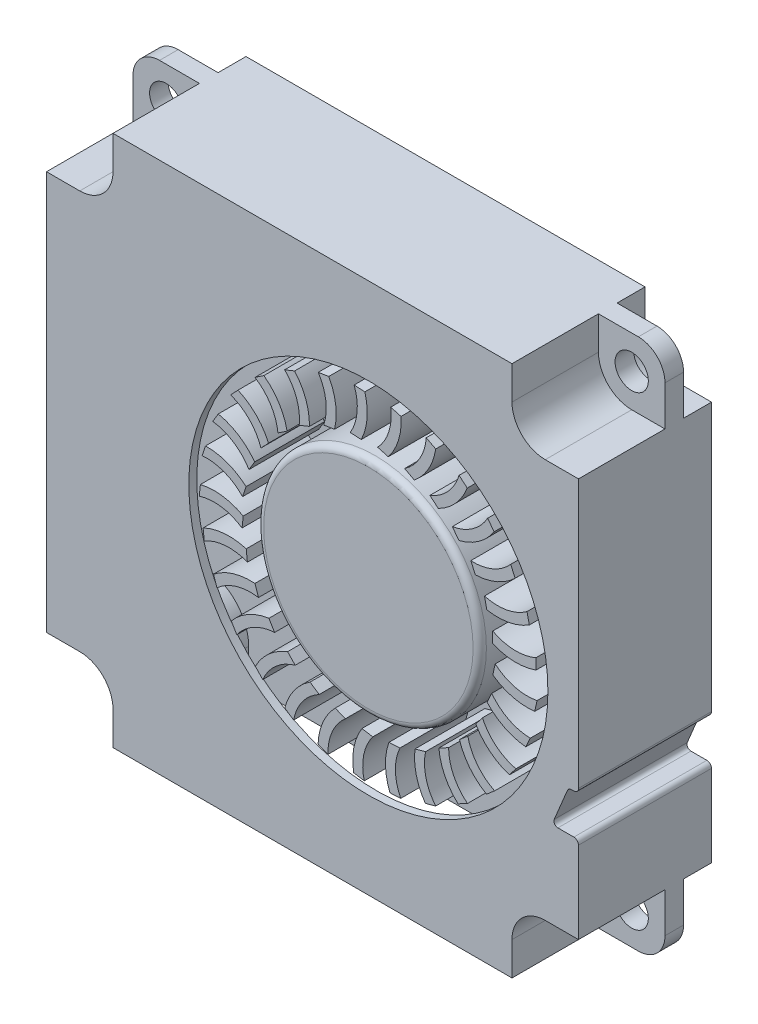
from build123d import *

# Parameters (mm, degrees)
SKETCH35_W                     = 40
SKETCH35_H                     = 40
BOSS_EXTRUDE31_DEPTH           = 10
SKETCH36_W                     = 28
SKETCH36_H                     = 8.6
CUT_EXTRUDE1_DEPTH             = 39
SKETCH41_W                     = 8.6
SKETCH41_H                     = 33
CUT_EXTRUDE2_DEPTH             = 5
SKETCH42_W                     = 8.6
SKETCH42_H                     = 33
CUT_EXTRUDE3_DEPTH             = 5
BOSS_EXTRUDE32_DEPTH           = 8.6
CUT_EXTRUDE4_DEPTH             = 11
SKETCH50_W                     = 5
SKETCH50_H                     = 5
BOSS_EXTRUDE33_DEPTH           = 8.6
SKETCH51_W                     = 5
SKETCH51_H                     = 5
BOSS_EXTRUDE34_DEPTH           = 8.6
SKETCH52_W                     = 5
SKETCH52_H                     = 5
CUT_EXTRUDE5_DEPTH             = 6.5
SKETCH53_W                     = 5
SKETCH53_H                     = 5
CUT_EXTRUDE6_DEPTH             = 6.5
SKETCH54_W                     = 5
SKETCH54_H                     = 5
CUT_EXTRUDE7_DEPTH             = 6.5
SKETCH55_W                     = 5
SKETCH55_H                     = 5
CUT_EXTRUDE8_DEPTH             = 6.5
SKETCH56_W                     = 5
SKETCH56_H                     = 5
CUT_EXTRUDE9_DEPTH             = 2.1
SKETCH57_W                     = 5
SKETCH57_H                     = 5
CUT_EXTRUDE10_DEPTH            = 2.1
SKETCH58_W                     = 5
SKETCH58_H                     = 5
CUT_EXTRUDE11_DEPTH            = 2.1
SKETCH59_W                     = 5
SKETCH59_H                     = 5
CUT_EXTRUDE12_DEPTH            = 2.1
F_2_5_2_5_DIAMETER_HOLE1_D     = 2.5
F_2_5_2_5_DIAMETER_HOLE1_DEPTH = 3.5
M24_CLEARANCE_HOLE1_D          = 27
M24_CLEARANCE_HOLE1_DEPTH      = 0.6
F_2_5_2_5_DIAMETER_HOLE2_D     = 2.5
F_2_5_2_5_DIAMETER_HOLE2_DEPTH = 7.9
FILLET2_R                      = 0.35
FILLET3_R                      = 2
FILLET4_R                      = 2.5
FILLET5_R                      = 3.5
BOSS_EXTRUDE35_DEPTH           = 2
BOSS_EXTRUDE36_DEPTH           = 5.25
BOSS_EXTRUDE37_DEPTH           = 5.25
BOSS_EXTRUDE38_DEPTH           = 5.25
BOSS_EXTRUDE39_DEPTH           = 5.25
BOSS_EXTRUDE40_DEPTH           = 5.25
BOSS_EXTRUDE41_DEPTH           = 5.25
BOSS_EXTRUDE42_DEPTH           = 5.25
BOSS_EXTRUDE43_DEPTH           = 5.25
BOSS_EXTRUDE44_DEPTH           = 5.25
BOSS_EXTRUDE45_DEPTH           = 5.25
BOSS_EXTRUDE46_DEPTH           = 5.25
BOSS_EXTRUDE47_DEPTH           = 5.25
BOSS_EXTRUDE48_DEPTH           = 5.25
BOSS_EXTRUDE49_DEPTH           = 5.25
BOSS_EXTRUDE50_DEPTH           = 5.25
BOSS_EXTRUDE51_DEPTH           = 5.25
BOSS_EXTRUDE52_DEPTH           = 5.25
BOSS_EXTRUDE53_DEPTH           = 5.25
BOSS_EXTRUDE54_DEPTH           = 5.25
BOSS_EXTRUDE55_DEPTH           = 5.25
BOSS_EXTRUDE56_DEPTH           = 5.25
BOSS_EXTRUDE57_DEPTH           = 5.25
BOSS_EXTRUDE58_DEPTH           = 5.25
BOSS_EXTRUDE59_DEPTH           = 5.25
BOSS_EXTRUDE60_DEPTH           = 5.25
BOSS_EXTRUDE61_DEPTH           = 5.25
BOSS_EXTRUDE62_DEPTH           = 5.25
BOSS_EXTRUDE63_DEPTH           = 5.25
BOSS_EXTRUDE64_DEPTH           = 5.25
SKETCH109_W                    = 8.375
SKETCH109_H                    = 5.25
FILLET6_R                      = 0.5


with BuildPart() as part:
    # Sketch35 → Boss-Extrude31 (new body)
    with BuildSketch(Plane.XY.offset(25.289004385)):
        with Locations((21.588376798, 27.405351981)):
            Rectangle(SKETCH35_W, SKETCH35_H)
    extrude(amount=-BOSS_EXTRUDE31_DEPTH)

    # Sketch36 → Cut-Extrude1 (cut)
    with BuildSketch(Plane.XZ.offset(-7.405351981)):
        with Locations((21.588376798, 20.389004385)):
            Rectangle(SKETCH36_W, SKETCH36_H)
    extrude(amount=-CUT_EXTRUDE1_DEPTH, mode=Mode.SUBTRACT)

    # Sketch41 → Cut-Extrude2 (cut)
    with BuildSketch(Plane(origin=(7.588376798, 0, 0), x_dir=(0, 0, -1), z_dir=(1, 0, 0))):
        with Locations((-20.389004385, 29.905351981)):
            Rectangle(SKETCH41_W, SKETCH41_H)
    extrude(amount=-CUT_EXTRUDE2_DEPTH, mode=Mode.SUBTRACT)

    # Sketch42 → Cut-Extrude3 (cut)
    with BuildSketch(Plane.ZY.offset(-35.588376798)):
        with Locations((20.389004385, 29.905351981)):
            Rectangle(SKETCH42_W, SKETCH42_H)
    extrude(amount=-CUT_EXTRUDE3_DEPTH, mode=Mode.SUBTRACT)

    # Sketch48 → Boss-Extrude32 (add)
    with BuildSketch(Plane(origin=(0, 0, 24.689004385), x_dir=(-1, 0, 0), z_dir=(0, 0, -1))):
        with BuildLine():
            Line((-40.588376798, 17.905351981), (-40.588376798, 22.824983073))
            ThreePointArc((-40.588376798, 22.824983073), (-40.138325562, 22.543385975), (-39.838376798, 22.105351981))
            Line((-39.838376798, 22.105351981), (-38.838376798, 19.705351981))
            ThreePointArc((-38.838376798, 19.705351981), (-38.956711416, 18.484241726), (-40.038376798, 17.905351981))
            Line((-40.038376798, 17.905351981), (-40.588376798, 17.905351981))
        make_face()
    extrude(amount=BOSS_EXTRUDE32_DEPTH)

    # Sketch49 → Cut-Extrude4 (cut, through all)
    with BuildSketch(Plane(origin=(0, 0, 15.289004385), x_dir=(-1, 0, 0), z_dir=(0, 0, -1))):
        with BuildLine():
            Line((-41.588376798, 18.905351981), (-40.038376798, 18.905351981))
            ThreePointArc((-40.038376798, 18.905351981), (-39.78876171, 19.038941923), (-39.761453721, 19.320736597))
            Line((-39.761453721, 19.320736597), (-40.838376798, 21.905351981))
            Line((-40.838376798, 21.905351981), (-41.588376798, 21.905351981))
            Line((-41.588376798, 21.905351981), (-41.588376798, 18.905351981))
        make_face()
    extrude(amount=-CUT_EXTRUDE4_DEPTH, mode=Mode.SUBTRACT)

    # Sketch50 → Boss-Extrude33 (add)
    with BuildSketch(Plane(origin=(0, 0, 24.689004385), x_dir=(-1, 0, 0), z_dir=(0, 0, -1))):
        with Locations((-38.088376798, 43.905351981)):
            Rectangle(SKETCH50_W, SKETCH50_H)
    extrude(amount=BOSS_EXTRUDE33_DEPTH)

    # Sketch51 → Boss-Extrude34 (add)
    with BuildSketch(Plane(origin=(0, 0, 24.689004385), x_dir=(-1, 0, 0), z_dir=(0, 0, -1))):
        with Locations((-5.088376798, 43.905351981)):
            Rectangle(SKETCH51_W, SKETCH51_H)
    extrude(amount=BOSS_EXTRUDE34_DEPTH)

    # Sketch52 → Cut-Extrude5 (cut)
    with BuildSketch(Plane.XY.offset(25.289004385)):
        with Locations((4.088376798, 9.905351981)):
            Rectangle(SKETCH52_W, SKETCH52_H)
    extrude(amount=-CUT_EXTRUDE5_DEPTH, mode=Mode.SUBTRACT)

    # Sketch53 → Cut-Extrude6 (cut)
    with BuildSketch(Plane.XY.offset(25.289004385)):
        with Locations((4.088376798, 44.905351981)):
            Rectangle(SKETCH53_W, SKETCH53_H)
    extrude(amount=-CUT_EXTRUDE6_DEPTH, mode=Mode.SUBTRACT)

    # Sketch54 → Cut-Extrude7 (cut)
    with BuildSketch(Plane.XY.offset(25.289004385)):
        with Locations((39.088376798, 9.905351981)):
            Rectangle(SKETCH54_W, SKETCH54_H)
    extrude(amount=-CUT_EXTRUDE7_DEPTH, mode=Mode.SUBTRACT)

    # Sketch55 → Cut-Extrude8 (cut)
    with BuildSketch(Plane.XY.offset(25.289004385)):
        with Locations((39.088376798, 44.905351981)):
            Rectangle(SKETCH55_W, SKETCH55_H)
    extrude(amount=-CUT_EXTRUDE8_DEPTH, mode=Mode.SUBTRACT)

    # Sketch56 → Cut-Extrude9 (cut)
    with BuildSketch(Plane(origin=(0, 0, 15.289004385), x_dir=(-1, 0, 0), z_dir=(0, 0, -1))):
        with Locations((-39.088376798, 44.905351981)):
            Rectangle(SKETCH56_W, SKETCH56_H)
    extrude(amount=-CUT_EXTRUDE9_DEPTH, mode=Mode.SUBTRACT)

    # Sketch57 → Cut-Extrude10 (cut)
    with BuildSketch(Plane(origin=(0, 0, 15.289004385), x_dir=(-1, 0, 0), z_dir=(0, 0, -1))):
        with Locations((-39.088376798, 9.905351981)):
            Rectangle(SKETCH57_W, SKETCH57_H)
    extrude(amount=-CUT_EXTRUDE10_DEPTH, mode=Mode.SUBTRACT)

    # Sketch58 → Cut-Extrude11 (cut)
    with BuildSketch(Plane(origin=(0, 0, 15.289004385), x_dir=(-1, 0, 0), z_dir=(0, 0, -1))):
        with Locations((-4.088376798, 44.905351981)):
            Rectangle(SKETCH58_W, SKETCH58_H)
    extrude(amount=-CUT_EXTRUDE11_DEPTH, mode=Mode.SUBTRACT)

    # Sketch59 → Cut-Extrude12 (cut)
    with BuildSketch(Plane(origin=(0, 0, 15.289004385), x_dir=(-1, 0, 0), z_dir=(0, 0, -1))):
        with Locations((-4.088376798, 9.905351981)):
            Rectangle(SKETCH59_W, SKETCH59_H)
    extrude(amount=-CUT_EXTRUDE12_DEPTH, mode=Mode.SUBTRACT)

    # Ø2.5 (2.5) Diameter Hole1
    with Locations(Plane.XY.offset(18.789004385)):
        with Locations((4.088376798, 44.905351981), (39.088376798, 9.905351981)):
            Hole(F_2_5_2_5_DIAMETER_HOLE1_D / 2, depth=F_2_5_2_5_DIAMETER_HOLE1_DEPTH)

    # M24 Clearance Hole1
    with Locations(Plane.XY.offset(25.289004385)):
        with Locations((25.788376798, 27.405351981)):
            Hole(M24_CLEARANCE_HOLE1_D / 2, depth=M24_CLEARANCE_HOLE1_DEPTH)

    # Ø2.5 (2.5) Diameter Hole2
    with Locations(Plane(origin=(0, 0, 17.389004385), x_dir=(-1, 0, 0), z_dir=(0, 0, -1))):
        with Locations((-4.088376798, 9.905351981), (-39.088376798, 44.905351981)):
            Hole(F_2_5_2_5_DIAMETER_HOLE2_D / 2, depth=F_2_5_2_5_DIAMETER_HOLE2_DEPTH)

    # Fillet2
    fillet2_edges = [part.edges().sort_by_distance(p)[0] for p in [
        (41.588376798, 18.905351981, 20.289004385),
        (41.588376798, 21.905351981, 20.289004385),
        (40.838376798, 21.905351981, 20.289004385),
    ]]
    fillet(fillet2_edges, radius=FILLET2_R)

    # Fillet3
    fillet3_edges = [part.edges().sort_by_distance(p)[0] for p in [
        (41.588376798, 47.405351981, 18.089004385),
        (41.588376798, 7.405351981, 18.089004385),
        (1.588376798, 47.405351981, 18.089004385),
        (1.588376798, 7.405351981, 18.089004385),
    ]]
    fillet(fillet3_edges, radius=FILLET3_R)

    # Fillet4
    fillet4_edges = [part.edges().sort_by_distance(p)[0] for p in [
        (6.588376798, 12.405351981, 22.039004385),
        (6.588376798, 42.405351981, 22.039004385),
        (36.588376798, 12.405351981, 22.039004385),
        (36.588376798, 42.405351981, 22.039004385),
        (36.588376798, 42.405351981, 16.339004385),
        (36.588376798, 12.405351981, 16.339004385),
        (6.588376798, 42.405351981, 16.339004385),
        (6.588376798, 12.405351981, 16.339004385),
    ]]
    fillet(fillet4_edges, radius=FILLET4_R)

    # Fillet5
    fillet5_edges = [part.edges().sort_by_distance(p)[0] for p in [
        (7.588376798, 41.405351981, 20.389004385),
        (7.588376798, 13.405351981, 20.389004385),
        (35.588376798, 13.405351981, 20.389004385),
        (35.588376798, 41.405351981, 20.389004385),
    ]]
    fillet(fillet5_edges, radius=FILLET5_R)


with BuildPart() as body_2:
    # Sketch72 → Boss-Extrude35 (new body)
    with BuildSketch(Plane.XY.offset(20.039004385)):
        with BuildLine():
            Line((38.389573748, 28.354150968), (38.388655241, 29.159859361))
            ThreePointArc((38.388655241, 29.159859361), (37.302982142, 28.86847563), (36.17972759, 28.911947059))
            ThreePointArc((36.17972759, 28.911947059), (36.04606607, 29.648075952), (35.860325155, 30.372818292))
            ThreePointArc((35.860325155, 30.372818292), (36.91590794, 30.584500617), (37.89100103, 31.040853431))
            Line((37.89100103, 31.040853431), (37.716900509, 31.827527357))
            ThreePointArc((37.716900509, 31.827527357), (36.719248733, 31.309568392), (35.612910176, 31.110556958))
            ThreePointArc((35.612910176, 31.110556958), (35.324127636, 31.80074229), (34.98693106, 32.468611751))
            ThreePointArc((34.98693106, 32.468611751), (35.972329464, 32.902264157), (36.826523054, 33.557563886))
            Line((36.826523054, 33.557563886), (36.487381266, 34.288419347))
            ThreePointArc((36.487381266, 34.288419347), (35.624399902, 33.568104333), (34.5867085, 33.135915589))
            ThreePointArc((34.5867085, 33.135915589), (34.156308091, 33.747885062), (33.683422792, 34.32765281))
            ThreePointArc((33.683422792, 34.32765281), (34.55256068, 34.962998193), (35.245913627, 35.78660375))
            Line((35.245913627, 35.78660375), (34.757588466, 36.427466757))
            ThreePointArc((34.757588466, 36.427466757), (34.069629561, 35.538476825), (33.149106613, 34.893319436))
            ThreePointArc((33.149106613, 34.893319436), (32.597213379, 35.398458037), (32.010750947, 35.863014776))
            ThreePointArc((32.010750947, 35.863014776), (32.722988398, 36.670345091), (33.223080289, 37.623745597))
            Line((33.223080289, 37.623745597), (32.608405296, 38.144650108))
            ThreePointArc((32.608405296, 38.144650108), (32.127637046, 37.128553437), (31.36732518, 36.300594246))
            ThreePointArc((31.36732518, 36.300594246), (30.719745036, 36.675282256), (30.047127803, 37.00290583))
            ThreePointArc((30.047127803, 37.00290583), (30.569161385, 37.944471209), (30.85260848, 38.983086715))
            Line((30.85260848, 38.983086715), (30.140325174, 39.359675814))
            ThreePointArc((30.140325174, 39.359675814), (29.889227767, 38.263983957), (29.324678322, 37.291937415))
            ThreePointArc((29.324678322, 37.291937415), (28.611691395, 37.518654839), (27.884370196, 37.694025933))
            ThreePointArc((27.884370196, 37.694025933), (28.191790198, 38.725799826), (28.245338825, 39.801065825))
            Line((28.245338825, 39.801065825), (27.468752783, 40.015730624))
            ThreePointArc((27.468752783, 40.015730624), (27.459067254, 38.891676913), (27.116677934, 37.820994837))
            ThreePointArc((27.116677934, 37.820994837), (26.371622702, 37.88914062), (25.623606266, 37.904059077))
            ThreePointArc((25.623606266, 37.904059077), (25.702038072, 38.977796883), (25.523184356, 40.039435132))
            Line((25.523184356, 40.039435132), (24.718607878, 40.082138145))
            ThreePointArc((24.718607878, 40.082138145), (24.950787113, 38.982282082), (24.846567662, 37.863028375))
            ThreePointArc((24.846567662, 37.863028375), (24.104282078, 37.769416096), (23.370546824, 37.623184345))
            ThreePointArc((23.370546824, 37.623184345), (23.216323049, 38.688679278), (22.813429992, 39.687048753))
            Line((22.813429992, 39.687048753), (22.018484179, 39.555793233))
            ThreePointArc((22.018484179, 39.555793233), (22.481671734, 38.531562866), (22.620495339, 37.416072588))
            ThreePointArc((22.620495339, 37.416072588), (21.915687851, 37.165079453), (21.230542424, 36.864535129))
            ThreePointArc((21.230542424, 36.864535129), (20.8508744, 37.871965829), (20.242780834, 38.760383883))
            Line((20.242780834, 38.760383883), (19.494636469, 38.461307193))
            ThreePointArc((19.494636469, 38.461307193), (20.167174209, 37.560594396), (20.542549631, 36.501026631))
            ThreePointArc((20.542549631, 36.501026631), (19.908176256, 36.104388801), (19.303657293, 35.663585021))
            ThreePointArc((19.303657293, 35.663585021), (18.716297876, 36.56584515), (17.931437579, 37.302770341))
            Line((17.931437579, 37.302770341), (17.265077061, 36.849856975))
            ThreePointArc((17.265077061, 36.849856975), (18.11551787, 36.114778076), (18.709892972, 35.160677037))
            ThreePointArc((18.709892972, 35.160677037), (18.175616302, 34.636940855), (17.67999044, 34.076489115))
            ThreePointArc((17.67999044, 34.076489115), (16.912403902, 34.831389991), (15.98747607, 35.382364517))
            Line((15.98747607, 35.382364517), (15.434057677, 34.7967922))
            ThreePointArc((15.434057677, 34.7967922), (16.422635886, 34.261718673), (17.208218349, 33.457697063))
            ThreePointArc((17.208218349, 33.457697063), (16.799020569, 32.831351851), (16.43546272, 32.177458252))
            ThreePointArc((16.43546272, 32.177458252), (15.523540556, 32.749701548), (14.501793786, 33.088962453))
            Line((14.501793786, 33.088962453), (14.087194746, 32.398111895))
            ThreePointArc((14.087194746, 32.398111895), (15.167685538, 32.088063183), (16.107742399, 31.471716159))
            ThreePointArc((16.107742399, 31.471716159), (15.842757142, 30.772049123), (15.628266868, 30.055289002))
            ThreePointArc((15.628266868, 30.055289002), (14.614649544, 30.41811726), (13.54385958, 30.52980108))
            Line((13.54385958, 30.52980108), (13.287466084, 29.765975686))
            ThreePointArc((13.287466084, 29.765975686), (14.409346909, 29.695449322), (15.459922154, 29.295596586))
            ThreePointArc((15.459922154, 29.295596586), (15.351539836, 28.555323379), (15.296146465, 27.809211643))
            ThreePointArc((15.296146465, 27.809211643), (14.2282296, 27.945659415), (13.15846539, 27.82454394))
            Line((13.15846539, 27.82454394), (13.072266112, 27.023459337))
            ThreePointArc((13.072266112, 27.023459337), (14.183079071, 27.195753054), (15.295048969, 27.031091276))
            ThreePointArc((15.295048969, 27.031091276), (15.348337426, 26.284826251), (15.45463109, 25.544250255))
            ThreePointArc((15.45463109, 25.544250255), (14.382349291, 25.447937396), (13.36363182, 25.09968585))
            Line((13.36363182, 25.09968585), (13.451657344, 24.298799863))
            ThreePointArc((13.451657344, 24.298799863), (14.499462057, 24.705857399), (15.620832131, 24.784085981))
            ThreePointArc((15.620832131, 24.784085981), (15.833299655, 24.06672366), (16.096310179, 23.366311915))
            ThreePointArc((16.096310179, 23.366311915), (15.069802151, 23.041741906), (14.149765517, 22.482638145))
            Line((14.149765517, 22.482638145), (14.407899865, 21.719399313))
            ThreePointArc((14.407899865, 21.719399313), (15.343702149, 22.342187111), (16.422038382, 22.65964817))
            ThreePointArc((16.422038382, 22.65964817), (16.783750226, 22.004731619), (17.191179532, 21.3772346))
            ThreePointArc((17.191179532, 21.3772346), (16.258443648, 20.839583975), (15.480107741, 20.095771068))
            Line((15.480107741, 20.095771068), (15.89628084, 19.40586759))
            ThreePointArc((15.89628084, 19.40586759), (16.676323619, 20.215264785), (17.661204206, 20.757114196))
            ThreePointArc((17.661204206, 20.757114196), (18.155247128, 20.195266584), (18.688044274, 19.670025354))
            ThreePointArc((18.688044274, 19.670025354), (17.892694228, 18.944434058), (17.29245317, 18.050691871))
            Line((17.29245317, 18.050691871), (17.847205227, 17.466382867))
            ThreePointArc((17.847205227, 17.466382867), (18.435014568, 18.424542945), (19.280387588, 19.165444431))
            ThreePointArc((19.280387588, 19.165444431), (19.88366069, 18.722937128), (20.516912673, 18.324511383))
            ThreePointArc((20.516912673, 18.324511383), (19.89613815, 17.444907259), (19.502058545, 16.443026184))
            Line((19.502058545, 16.443026184), (20.169449971, 15.991633294))
            ThreePointArc((20.169449971, 15.991633294), (20.537540563, 17.053753754), (21.203877313, 17.959063585))
            ThreePointArc((21.203877313, 17.959063585), (21.888172215, 17.656587742), (22.592268876, 17.403607426))
            ThreePointArc((22.592268876, 17.403607426), (22.175096602, 16.411119785), (22.005605175, 15.347946667))
            Line((22.005605175, 15.347946667), (22.754429489, 15.05057652))
            ThreePointArc((22.754429489, 15.05057652), (22.885589824, 16.166993791), (23.341733138, 17.194380686))
            ThreePointArc((23.341733138, 17.194380686), (24.075052971, 17.046079736), (24.817071533, 16.950373929))
            ThreePointArc((24.817071533, 16.950373929), (24.62300802, 15.89141039), (24.686030002, 14.816658021))
            Line((24.686030002, 14.816658021), (25.481273011, 14.687215316))
            ThreePointArc((25.481273011, 14.687215316), (25.369370178, 15.805726966), (25.593991302, 16.907151456))
            ThreePointArc((25.593991302, 16.907151456), (26.342046844, 16.919959787), (27.087291344, 16.986003585))
            ThreePointArc((27.087291344, 16.986003585), (27.125410787, 15.910080107), (27.417999339, 14.874002714))
            Line((27.417999339, 14.874002714), (28.222476364, 14.918540048))
            ThreePointArc((28.222476364, 14.918540048), (27.872742816, 15.986845716), (27.855338715, 17.110806414))
            ThreePointArc((27.855338715, 17.110806414), (28.583151722, 17.284125123), (29.296775355, 17.508830392))
            ThreePointArc((29.296775355, 17.508830392), (29.56529533, 16.46625596), (30.073769338, 15.517299372))
            Line((30.073769338, 15.517299372), (30.849863927, 15.733734227))
            ThreePointArc((30.849863927, 15.733734227), (30.278652815, 16.701881127), (30.020037287, 17.795822882))
            ThreePointArc((30.020037287, 17.795822882), (30.693576031, 18.121547778), (31.342210549, 18.49440755))
            ThreePointArc((31.342210549, 18.49440755), (31.828575361, 17.533931785), (32.529159145, 16.716468156))
            Line((32.529159145, 16.716468156), (33.240581977, 17.09468028))
            ThreePointArc((33.240581977, 17.09468028), (32.474602499, 17.91739894), (31.986868117, 18.93017025))
            ThreePointArc((31.986868117, 18.93017025), (32.574638675, 19.3930708), (33.12795465, 19.896650565))
            ThreePointArc((33.12795465, 19.896650565), (33.80942242, 19.063184248), (34.669357461, 18.415437268))
            Line((34.669357461, 18.415437268), (35.282843196, 18.937741883))
            ThreePointArc((35.282843196, 18.937741883), (34.357911699, 19.576562891), (33.663864382, 20.460807697))
            ThreePointArc((33.663864382, 20.460807697), (34.138383257, 21.039239184), (34.570508247, 21.649992113))
            ThreePointArc((34.570508247, 21.649992113), (35.415214301, 20.982507202), (36.394290992, 20.534764801))
            Line((36.394290992, 20.534764801), (36.881153718, 21.176739522))
            ThreePointArc((36.881153718, 21.176739522), (35.840518973, 21.60179232), (34.972611601, 22.316164316))
            ThreePointArc((34.972611601, 22.316164316), (35.311690816, 22.983079928), (35.602419139, 23.672447892))
            ThreePointArc((35.602419139, 23.672447892), (36.57086596, 23.20215524), (37.623303762, 22.975353354))
            Line((37.623303762, 22.975353354), (37.960778321, 23.706980158))
            ThreePointArc((37.960778321, 23.706980158), (36.85309925, 23.898389748), (35.851914207, 24.409485694))
            ThreePointArc((35.851914207, 24.409485694), (36.039698797, 25.133701198), (36.175436318, 25.869450118))
            ThreePointArc((36.175436318, 25.869450118), (37.222340409, 25.618340085), (38.298928502, 25.62308372))
            Line((38.298928502, 25.62308372), (38.471234956, 26.41015255))
            ThreePointArc((38.471234956, 26.41015255), (37.348305403, 26.358968832), (36.26065699, 26.64289045))
            ThreePointArc((36.26065699, 26.64289045), (36.288366354, 27.390542333), (36.262766138, 28.138269407))
            ThreePointArc((36.262766138, 28.138269407), (37.339175428, 28.118083621), (38.389573748, 28.354150968))
        make_face()
    extrude(amount=-BOSS_EXTRUDE35_DEPTH)


with BuildPart() as body_3:
    # Sketch73 → Boss-Extrude36 (new body)
    with BuildSketch(Plane.XY.offset(20.039004385)):
        with BuildLine():
            Line((38.388655241, 29.159859361), (38.389573748, 28.354150968))
            ThreePointArc((38.389573748, 28.354150968), (36.755812014, 28.096926162), (35.13946544, 28.447305608))
            Line((35.13946544, 28.447305608), (35.138520203, 29.276461267))
            ThreePointArc((35.138520203, 29.276461267), (36.750289542, 28.847489865), (38.388655241, 29.159859361))
        make_face()
    extrude(amount=BOSS_EXTRUDE36_DEPTH)


with BuildPart() as body_4:
    # Sketch74 → Boss-Extrude37 (new body)
    with BuildSketch(Plane.XY.offset(20.039004385)):
        with BuildLine():
            Line((38.471234956, 26.41015255), (38.298928502, 25.62308372))
            ThreePointArc((38.298928502, 25.62308372), (36.648067479, 25.723083165), (35.144831414, 26.41273767))
            Line((35.144831414, 26.41273767), (35.322152233, 27.222711328))
            ThreePointArc((35.322152233, 27.222711328), (36.804023129, 26.457286274), (38.471234956, 26.41015255))
        make_face()
    extrude(amount=BOSS_EXTRUDE37_DEPTH)


with BuildPart() as body_5:
    # Sketch75 → Boss-Extrude38 (new body)
    with BuildSketch(Plane.XY.offset(20.039004385)):
        with BuildLine():
            Line((37.960778321, 23.706980158), (37.623303762, 22.975353354))
            ThreePointArc((37.623303762, 22.975353354), (36.032535878, 23.427901189), (34.712699969, 24.424583273))
            Line((34.712699969, 24.424583273), (35.059995519, 25.177501463))
            ThreePointArc((35.059995519, 25.177501463), (36.342677337, 24.111413183), (37.960778321, 23.706980158))
        make_face()
    extrude(amount=BOSS_EXTRUDE38_DEPTH)


with BuildPart() as body_6:
    # Sketch76 → Boss-Extrude39 (new body)
    with BuildSketch(Plane.XY.offset(20.039004385)):
        with BuildLine():
            Line((36.881153718, 21.176739522), (36.394290992, 20.534764801))
            ThreePointArc((36.394290992, 20.534764801), (34.937998784, 21.318700391), (33.863277091, 22.575806309))
            Line((33.863277091, 22.575806309), (34.364308219, 23.236463412))
            ThreePointArc((34.364308219, 23.236463412), (35.387824182, 21.919561009), (36.881153718, 21.176739522))
        make_face()
    extrude(amount=BOSS_EXTRUDE39_DEPTH)


with BuildPart() as body_7:
    # Sketch77 → Boss-Extrude40 (new body)
    with BuildSketch(Plane.XY.offset(20.039004385)):
        with BuildLine():
            Line((35.282843196, 18.937741883), (34.669357461, 18.415437268))
            ThreePointArc((34.669357461, 18.415437268), (33.415635535, 19.494104657), (32.63628085, 20.952853532))
            Line((32.63628085, 20.952853532), (33.267619897, 21.490357957))
            ThreePointArc((33.267619897, 21.490357957), (33.984111536, 19.984218323), (35.282843196, 18.937741883))
        make_face()
    extrude(amount=BOSS_EXTRUDE40_DEPTH)


with BuildPart() as body_8:
    # Sketch78 → Boss-Extrude41 (new body)
    with BuildSketch(Plane.XY.offset(20.039004385)):
        with BuildLine():
            Line((33.240581977, 17.09468028), (32.529159145, 16.716468156))
            ThreePointArc((32.529159145, 16.716468156), (31.536630144, 18.039430055), (31.089084227, 19.631612412))
            Line((31.089084227, 19.631612412), (31.821210481, 20.020831049))
            ThreePointArc((31.821210481, 20.020831049), (32.197175443, 18.3958796), (33.240581977, 17.09468028))
        make_face()
    extrude(amount=BOSS_EXTRUDE41_DEPTH)


with BuildPart() as body_9:
    # Sketch79 → Boss-Extrude42 (new body)
    with BuildSketch(Plane.XY.offset(20.039004385)):
        with BuildLine():
            Line((30.849863927, 15.733734227), (30.073769338, 15.517299372))
            ThreePointArc((30.073769338, 15.517299372), (29.388842816, 17.022695553), (29.294032415, 18.673862713))
            Line((29.294032415, 18.673862713), (30.092712466, 18.896596133))
            ThreePointArc((30.092712466, 18.896596133), (30.110571048, 17.228813791), (30.849863927, 15.733734227))
        make_face()
    extrude(amount=BOSS_EXTRUDE42_DEPTH)


with BuildPart() as body_10:
    # Sketch80 → Boss-Extrude43 (new body)
    with BuildSketch(Plane.XY.offset(20.039004385)):
        with BuildLine():
            Line((28.222476364, 14.918540048), (27.417999339, 14.874002714))
            ThreePointArc((27.417999339, 14.874002714), (27.072701698, 16.491442526), (27.335060043, 18.124387749))
            Line((27.335060043, 18.124387749), (28.1629485, 18.170221183))
            ThreePointArc((28.1629485, 18.170221183), (27.821865654, 16.537591599), (28.222476364, 14.918540048))
        make_face()
    extrude(amount=BOSS_EXTRUDE43_DEPTH)


with BuildPart() as body_11:
    # Sketch81 → Boss-Extrude44 (new body)
    with BuildSketch(Plane.XY.offset(20.039004385)):
        with BuildLine():
            Line((25.481273011, 14.687215316), (24.686030002, 14.816658021))
            ThreePointArc((24.686030002, 14.816658021), (24.696506975, 16.470511775), (25.303766482, 18.008880357))
            Line((25.303766482, 18.008880357), (26.1221522, 17.875670685))
            ThreePointArc((26.1221522, 17.875670685), (25.438076581, 16.354533803), (25.481273011, 14.687215316))
        make_face()
    extrude(amount=BOSS_EXTRUDE44_DEPTH)


with BuildPart() as body_12:
    # Sketch82 → Boss-Extrude45 (new body)
    with BuildSketch(Plane.XY.offset(20.039004385)):
        with BuildLine():
            Line((22.754429489, 15.05057652), (22.005605175, 15.347946667))
            ThreePointArc((22.005605175, 15.347946667), (22.371366872, 16.960881999), (23.29513276, 18.332741535))
            Line((23.29513276, 18.332741535), (24.065748933, 18.026717493))
            ThreePointArc((24.065748933, 18.026717493), (23.070667157, 16.688199983), (22.754429489, 15.05057652))
        make_face()
    extrude(amount=BOSS_EXTRUDE45_DEPTH)


with BuildPart() as body_13:
    # Sketch83 → Boss-Extrude46 (new body)
    with BuildSketch(Plane.XY.offset(20.039004385)):
        with BuildLine():
            Line((20.169449971, 15.991633294), (19.502058545, 16.443026184))
            ThreePointArc((19.502058545, 16.443026184), (20.206002355, 17.939624031), (21.403080359, 19.080827894))
            Line((21.403080359, 19.080827894), (22.08989383, 18.616298826))
            ThreePointArc((22.08989383, 18.616298826), (20.830334815, 17.522988279), (20.169449971, 15.991633294))
        make_face()
    extrude(amount=BOSS_EXTRUDE46_DEPTH)


with BuildPart() as body_14:
    # Sketch84 → Boss-Extrude47 (new body)
    with BuildSketch(Plane.XY.offset(20.039004385)):
        with BuildLine():
            Line((17.847205227, 17.466382867), (17.29245317, 18.050691871))
            ThreePointArc((17.29245317, 18.050691871), (18.301663463, 19.360972982), (19.716079545, 20.218159747))
            Line((19.716079545, 20.218159747), (20.286975681, 19.616846516))
            ThreePointArc((20.286975681, 19.616846516), (18.821835006, 18.819864918), (17.847205227, 17.466382867))
        make_face()
    extrude(amount=BOSS_EXTRUDE47_DEPTH)


with BuildPart() as body_15:
    # Sketch85 → Boss-Extrude48 (new body)
    with BuildSketch(Plane.XY.offset(20.039004385)):
        with BuildLine():
            Line((15.89628084, 19.40586759), (15.480107741, 20.095771068))
            ThreePointArc((15.480107741, 20.095771068), (16.747394966, 21.158468154), (18.313012602, 21.691556721))
            Line((18.313012602, 21.691556721), (18.741296933, 20.981576066))
            ThreePointArc((18.741296933, 20.981576066), (17.139082948, 20.518189391), (15.89628084, 19.40586759))
        make_face()
    extrude(amount=BOSS_EXTRUDE48_DEPTH)


with BuildPart() as body_16:
    # Sketch86 → Boss-Extrude49 (new body)
    with BuildSketch(Plane.XY.offset(20.039004385)):
        with BuildLine():
            Line((14.407899865, 21.719399313), (14.149765517, 22.482638145))
            ThreePointArc((14.149765517, 22.482638145), (15.61587273, 23.248060671), (17.25948538, 23.432124411))
            Line((17.25948538, 23.432124411), (17.525131808, 22.646674238))
            ThreePointArc((17.525131808, 22.646674238), (15.860762258, 22.538549931), (14.407899865, 21.719399313))
        make_face()
    extrude(amount=BOSS_EXTRUDE49_DEPTH)


with BuildPart() as body_17:
    # Sketch87 → Boss-Extrude50 (new body)
    with BuildSketch(Plane.XY.offset(20.039004385)):
        with BuildLine():
            Line((13.451657344, 24.298799863), (13.36363182, 25.09968585))
            ThreePointArc((13.36363182, 25.09968585), (14.960005479, 25.532043509), (16.604759642, 25.358475807))
            Line((16.604759642, 25.358475807), (16.695346835, 24.534282892))
            ThreePointArc((16.695346835, 24.534282892), (15.04664579, 24.786476727), (13.451657344, 24.298799863))
        make_face()
    extrude(amount=BOSS_EXTRUDE50_DEPTH)


with BuildPart() as body_18:
    # Sketch88 → Boss-Extrude51 (new body)
    with BuildSketch(Plane.XY.offset(20.039004385)):
        with BuildLine():
            Line((13.072266112, 27.023459337), (13.15846539, 27.82454394))
            ThreePointArc((13.15846539, 27.82454394), (14.810460836, 27.903620169), (16.379449636, 27.380536857))
            Line((16.379449636, 27.380536857), (16.290741836, 26.556139546))
            ThreePointArc((16.290741836, 26.556139546), (14.734800725, 27.156859218), (13.072266112, 27.023459337))
        make_face()
    extrude(amount=BOSS_EXTRUDE51_DEPTH)


with BuildPart() as body_19:
    # Sketch89 → Boss-Extrude52 (new body)
    with BuildSketch(Plane.XY.offset(20.039004385)):
        with BuildLine():
            Line((13.287466084, 29.765975686), (13.54385958, 30.52980108))
            ThreePointArc((13.54385958, 30.52980108), (15.174231342, 30.251898363), (16.594090606, 29.403758235))
            Line((16.594090606, 29.403758235), (16.330235692, 28.61770443))
            ThreePointArc((16.330235692, 28.61770443), (14.939808592, 29.538860955), (13.287466084, 29.765975686))
        make_face()
    extrude(amount=BOSS_EXTRUDE52_DEPTH)


with BuildPart() as body_20:
    # Sketch90 → Boss-Extrude53 (new body)
    with BuildSketch(Plane.XY.offset(20.039004385)):
        with BuildLine():
            Line((14.087194746, 32.398111895), (14.501793786, 33.088962453))
            ThreePointArc((14.501793786, 33.088962453), (16.034307493, 32.467075211), (17.23864618, 31.333536357))
            Line((17.23864618, 31.333536357), (16.811981715, 30.62258106))
            ThreePointArc((16.811981715, 30.62258106), (15.652083451, 31.821102184), (14.087194746, 32.398111895))
        make_face()
    extrude(amount=BOSS_EXTRUDE53_DEPTH)


with BuildPart() as body_21:
    # Sketch91 → Boss-Extrude54 (new body)
    with BuildSketch(Plane.XY.offset(20.039004385)):
        with BuildLine():
            Line((15.434057677, 34.7967922), (15.98747607, 35.382364517))
            ThreePointArc((15.98747607, 35.382364517), (17.350473084, 34.445571507), (18.282977655, 33.079636944))
            Line((18.282977655, 33.079636944), (17.713453995, 32.477023635))
            ThreePointArc((17.713453995, 32.477023635), (16.838320122, 33.896867841), (15.434057677, 34.7967922))
        make_face()
    extrude(amount=BOSS_EXTRUDE54_DEPTH)


with BuildPart() as body_22:
    # Sketch92 → Boss-Extrude55 (new body)
    with BuildSketch(Plane.XY.offset(20.039004385)):
        with BuildLine():
            Line((17.265077061, 36.849856975), (17.931437579, 37.302770341))
            ThreePointArc((17.931437579, 37.302770341), (19.061185675, 36.094874963), (19.678253252, 34.560414273))
            Line((19.678253252, 34.560414273), (18.992500691, 34.09432048))
            ThreePointArc((18.992500691, 34.09432048), (18.443051495, 35.669097431), (17.265077061, 36.849856975))
        make_face()
    extrude(amount=BOSS_EXTRUDE55_DEPTH)


with BuildPart() as body_23:
    # Sketch93 → Boss-Extrude56 (new body)
    with BuildSketch(Plane.XY.offset(20.039004385)):
        with BuildLine():
            Line((19.494636469, 38.461307193), (20.242780834, 38.760383883))
            ThreePointArc((20.242780834, 38.760383883), (21.086454245, 37.337865982), (21.359231436, 35.706628841))
            Line((21.359231436, 35.706628841), (20.589315, 35.398848592))
            ThreePointArc((20.589315, 35.398848592), (20.391242116, 37.054923469), (19.494636469, 38.461307193))
        make_face()
    extrude(amount=BOSS_EXTRUDE56_DEPTH)


with BuildPart() as body_24:
    # Sketch94 → Boss-Extrude57 (new body)
    with BuildSketch(Plane.XY.offset(20.039004385)):
        with BuildLine():
            Line((37.716900509, 31.827527357), (37.89100103, 31.040853431))
            ThreePointArc((37.89100103, 31.040853431), (36.350731467, 30.438431918), (34.696852954, 30.433152953))
            Line((34.696852954, 30.433152953), (34.517685859, 31.242720215))
            ThreePointArc((34.517685859, 31.242720215), (36.183989098, 31.17026069), (37.716900509, 31.827527357))
        make_face()
    extrude(amount=BOSS_EXTRUDE57_DEPTH)


with BuildPart() as body_25:
    # Sketch95 → Boss-Extrude58 (new body)
    with BuildSketch(Plane.XY.offset(20.039004385)):
        with BuildLine():
            Line((36.487381266, 34.288419347), (36.826523054, 33.557563886))
            ThreePointArc((36.826523054, 33.557563886), (35.451766956, 32.638114227), (33.837690024, 32.27742369))
            Line((33.837690024, 32.27742369), (33.488678726, 33.02954809))
            ThreePointArc((33.488678726, 33.02954809), (35.131601377, 33.316988569), (36.487381266, 34.288419347))
        make_face()
    extrude(amount=BOSS_EXTRUDE58_DEPTH)


with BuildPart() as body_26:
    # Sketch96 → Boss-Extrude59 (new body)
    with BuildSketch(Plane.XY.offset(20.039004385)):
        with BuildLine():
            Line((34.757588466, 36.427466757), (35.245913627, 35.78660375))
            ThreePointArc((35.245913627, 35.78660375), (34.10095306, 34.59311839), (32.602150154, 33.893881768))
            Line((32.602150154, 33.893881768), (32.099614032, 34.553394805))
            ThreePointArc((32.099614032, 34.553394805), (33.642334858, 35.187294891), (34.757588466, 36.427466757))
        make_face()
    extrude(amount=BOSS_EXTRUDE59_DEPTH)


with BuildPart() as body_27:
    # Sketch97 → Boss-Extrude60 (new body)
    with BuildSketch(Plane.XY.offset(20.039004385)):
        with BuildLine():
            Line((32.608405296, 38.144650108), (33.223080289, 37.623745597))
            ThreePointArc((33.223080289, 37.623745597), (32.361452338, 36.212030584), (31.048005815, 35.206943405))
            Line((31.048005815, 35.206943405), (30.415442901, 35.743006983))
            ThreePointArc((30.415442901, 35.743006983), (31.78582599, 36.693726212), (32.608405296, 38.144650108))
        make_face()
    extrude(amount=BOSS_EXTRUDE60_DEPTH)


with BuildPart() as body_28:
    # Sketch98 → Boss-Extrude61 (new body)
    with BuildSketch(Plane.XY.offset(20.039004385)):
        with BuildLine():
            Line((30.140325174, 39.359675814), (30.85260848, 38.983086715))
            ThreePointArc((30.85260848, 38.983086715), (30.314601908, 37.419152275), (29.247927069, 36.155211298))
            Line((29.247927069, 36.155211298), (28.5149153, 36.542759679))
            ThreePointArc((28.5149153, 36.542759679), (29.648883064, 37.765843477), (30.140325174, 39.359675814))
        make_face()
    extrude(amount=BOSS_EXTRUDE61_DEPTH)


with BuildPart() as body_29:
    # Sketch99 → Boss-Extrude62 (new body)
    with BuildSketch(Plane.XY.offset(20.039004385)):
        with BuildLine():
            Line((27.468752783, 40.015730624), (28.245338825, 39.801065825))
            ThreePointArc((28.245338825, 39.801065825), (28.056110223, 38.158039793), (27.286083597, 36.694345495))
            Line((27.286083597, 36.694345495), (26.48689779, 36.915257347))
            ThreePointArc((26.48689779, 36.915257347), (27.331427155, 38.353515675), (27.468752783, 40.015730624))
        make_face()
    extrude(amount=BOSS_EXTRUDE62_DEPTH)


with BuildPart() as body_30:
    # Sketch100 → Boss-Extrude63 (new body)
    with BuildSketch(Plane.XY.offset(20.039004385)):
        with BuildLine():
            Line((24.718607878, 40.082138145), (25.523184356, 40.039435132))
            ThreePointArc((25.523184356, 40.039435132), (25.691581844, 38.39414358), (25.25420902, 36.799136678))
            Line((25.25420902, 36.799136678), (24.426218215, 36.84308241))
            ThreePointArc((24.426218215, 36.84308241), (24.941819927, 38.429263906), (24.718607878, 40.082138145))
        make_face()
    extrude(amount=BOSS_EXTRUDE63_DEPTH)


with BuildPart() as body_31:
    # Sketch101 → Boss-Extrude64 (new body)
    with BuildSketch(Plane.XY.offset(20.039004385)):
        with BuildLine():
            Line((22.018484179, 39.555793233), (22.813429992, 39.687048753))
            ThreePointArc((22.813429992, 39.687048753), (23.331579489, 38.116423685), (23.247311534, 36.464684929))
            Line((23.247311534, 36.464684929), (22.429231661, 36.329609686))
            ThreePointArc((22.429231661, 36.329609686), (22.591796756, 37.989546268), (22.018484179, 39.555793233))
        make_face()
    extrude(amount=BOSS_EXTRUDE64_DEPTH)


with BuildPart() as body_32:
    # Sketch109 → Revolve2 (revolve)
    with BuildSketch(Plane(origin=(0, 27.405351981, 0), x_dir=(-1, 0, 0), z_dir=(0, -1, 0))):
        with Locations((-29.975876798, -22.664004385)):
            Rectangle(SKETCH109_W, SKETCH109_H)
    revolve(axis=Axis((25.788376798, 27.405351981, 25.289004385), (0, 0, -1)))

    # Fillet6
    fillet6_edges = [body_32.edges().sort_by_distance(p)[0] for p in [
        (17.413376798, 27.405351981, 25.289004385),
    ]]
    fillet(fillet6_edges, radius=FILLET6_R)


solid = Compound([part.part, body_2.part, body_3.part, body_4.part, body_5.part, body_6.part, body_7.part, body_8.part, body_9.part, body_10.part, body_11.part, body_12.part, body_13.part, body_14.part, body_15.part, body_16.part, body_17.part, body_18.part, body_19.part, body_20.part, body_21.part, body_22.part, body_23.part, body_24.part, body_25.part, body_26.part, body_27.part, body_28.part, body_29.part, body_30.part, body_31.part, body_32.part])
